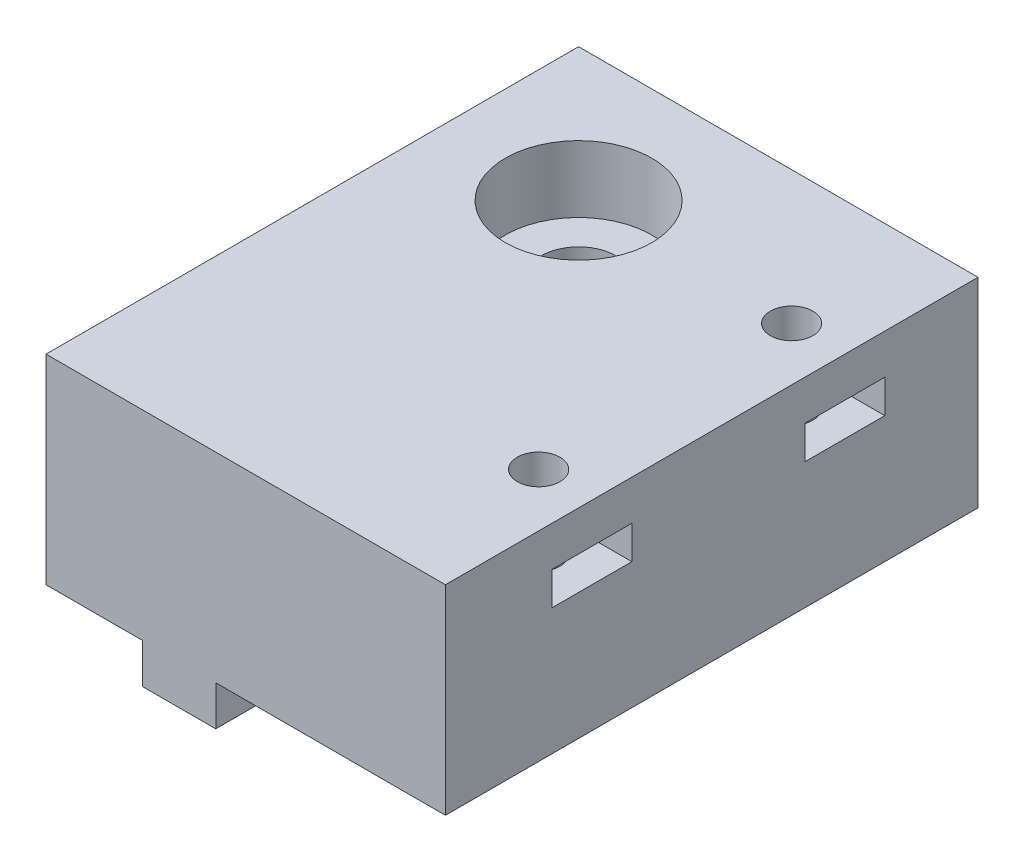
from build123d import *

# Parameters (mm, degrees)
SKETCH1_W           = 30
SKETCH1_H           = 40
BOSS_EXTRUDE1_DEPTH = 15
SKETCH5_R           = 1.6
CUT_EXTRUDE3_DEPTH  = 16
SKETCH6_W           = 6
SKETCH6_H           = 2.5
CUT_EXTRUDE4_DEPTH  = 8
SKETCH10_R          = 2.8
CUT_EXTRUDE7_DEPTH  = 16
SKETCH11_R          = 5.5
CUT_EXTRUDE8_DEPTH  = 5
SKETCH12_W          = 5.5
SKETCH12_H          = 22.5
SKETCH12_H_2        = 2.5
BOSS_EXTRUDE7_DEPTH = 3


with BuildPart() as part:
    # Sketch1 → Boss-Extrude1 (new body)
    with BuildSketch(Plane(origin=(0, 0, 0), x_dir=(1, 0, 0), z_dir=(0, 1, 0))):
        with Locations((14.30324178, 20)):
            Rectangle(SKETCH1_W, SKETCH1_H)
    extrude(amount=BOSS_EXTRUDE1_DEPTH)

    # Sketch5 → Cut-Extrude3 (cut, through all)
    with BuildSketch(Plane(origin=(0, 15, 0), x_dir=(1, 0, 0), z_dir=(0, 1, 0))):
        with Locations((25.30324178, 11)):
            Circle(SKETCH5_R)
        with Locations((25.30324178, 30)):
            Circle(SKETCH5_R)
    extrude(amount=-CUT_EXTRUDE3_DEPTH, mode=Mode.SUBTRACT)

    # Sketch6 → Cut-Extrude4 (cut)
    with BuildSketch(Plane(origin=(29.30324178, 0, 0), x_dir=(0, 0, -1), z_dir=(1, 0, 0))):
        with Locations((11, 10.75)):
            Rectangle(SKETCH6_W, SKETCH6_H)
        with Locations((30, 10.75)):
            Rectangle(SKETCH6_W, SKETCH6_H)
    extrude(amount=-CUT_EXTRUDE4_DEPTH, mode=Mode.SUBTRACT)

    # Sketch10 → Cut-Extrude7 (cut, through all)
    with BuildSketch(Plane(origin=(0, 15, 0), x_dir=(1, 0, 0), z_dir=(0, 1, 0))):
        with Locations((9.30324178, 30)):
            Circle(SKETCH10_R)
    extrude(amount=-CUT_EXTRUDE7_DEPTH, mode=Mode.SUBTRACT)

    # Sketch11 → Cut-Extrude8 (cut)
    with BuildSketch(Plane(origin=(0, 15, 0), x_dir=(1, 0, 0), z_dir=(0, 1, 0))):
        with Locations((9.30324178, 30)):
            Circle(SKETCH11_R)
    extrude(amount=-CUT_EXTRUDE8_DEPTH, mode=Mode.SUBTRACT)

    # Sketch12 → Boss-Extrude7 (add)
    with BuildSketch(Plane.XZ):
        with Locations((9.30324178, -11.25)):
            Rectangle(SKETCH12_W, SKETCH12_H)
        with Locations((9.30324178, -38.75)):
            Rectangle(SKETCH12_W, SKETCH12_H_2)
    extrude(amount=BOSS_EXTRUDE7_DEPTH)


solid = part.part
